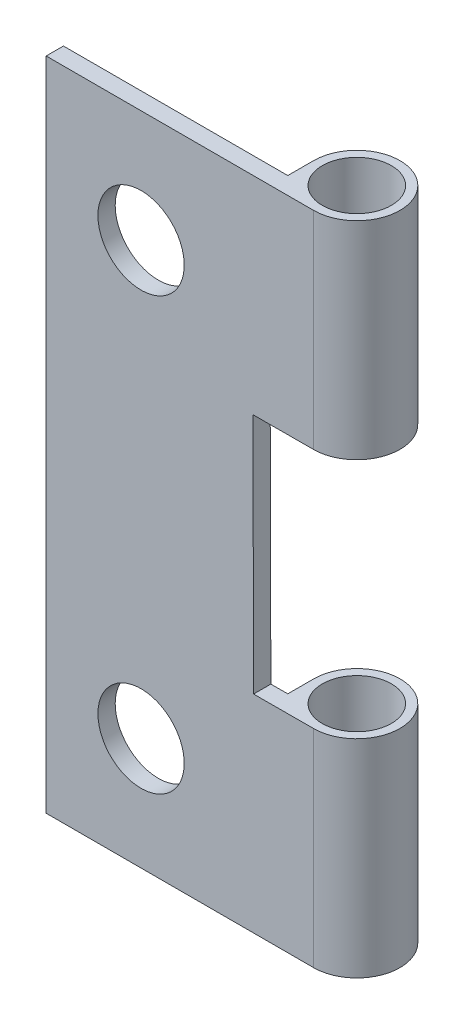
from build123d import *

# Parameters (mm, degrees)
SKETCH_1_W          = 13
SKETCH_1_H          = 38
EXTRUDE_1_DEPTH     = 1
SKETCH_2_R          = 2
EXTRUDE_2_DEPTH     = 38
CUT_EXTRUDE_1_DEPTH = 10
SKETCH_4_R          = 2.5
CUT_EXTRUDE_2_DEPTH = 2


with BuildPart() as part:
    # 草图1 → 凸台-拉伸1 (new body)
    with BuildSketch(Plane.XY):
        Rectangle(SKETCH_1_W, SKETCH_1_H)
    extrude(amount=EXTRUDE_1_DEPTH)

    # 草图2 → 凸台-拉伸2 (add)
    with BuildSketch(Plane(origin=(0, 19, 0), x_dir=(1, 0, 0), z_dir=(0, 1, 0))):
        with BuildLine():
            Line((6.5, -1), (9, -1))
            ThreePointArc((9, -1), (10.767766953, 3.267766953), (6.5, 1.5))
            Line((6.5, 1.5), (6.5, -1))
        make_face()
        with Locations((9, 1.5)):
            Circle(SKETCH_2_R, mode=Mode.SUBTRACT)
    extrude(amount=-EXTRUDE_2_DEPTH)

    # 草图3 → 切除-拉伸1 (cut)
    with BuildSketch(Plane.XY.offset(1)):
        Polygon((5.519068854, -7.009502005), (12.519042916, -6.99044612), (12.480931146, 7.009502005), (5.480957084, 6.99044612), align=None)
    extrude(amount=-CUT_EXTRUDE_1_DEPTH, mode=Mode.SUBTRACT)

    # 草图4 → 切除-拉伸2 (cut)
    with BuildSketch(Plane(origin=(0, 0, 0), x_dir=(-1, 0, 0), z_dir=(0, 0, -1))):
        with Locations((1, 12.5)):
            Circle(SKETCH_4_R)
        with Locations((1, -12.5)):
            Circle(SKETCH_4_R)
    extrude(amount=-CUT_EXTRUDE_2_DEPTH, mode=Mode.SUBTRACT)


solid = part.part
